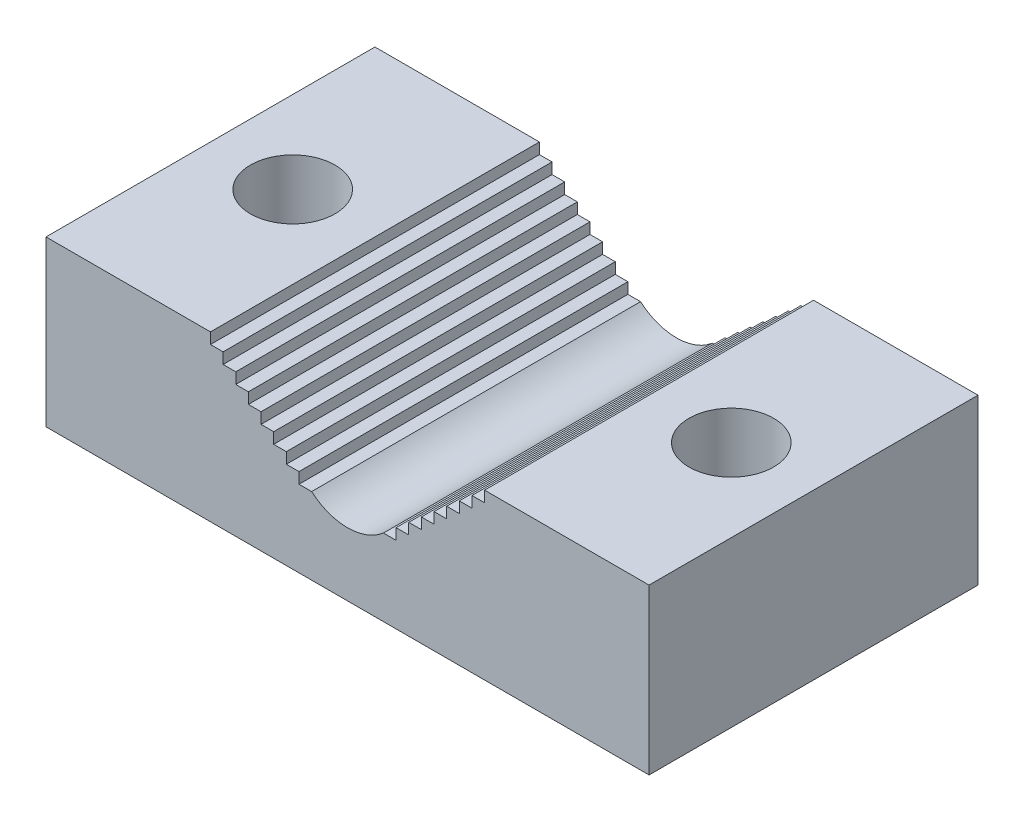
from build123d import *

# Parameters (mm, degrees)
SKETCH1_W               = 69.85
SKETCH1_H               = 19.05
BOSS_EXTRUDE1_DEPTH     = 38.1
CUT_EXTRUDE1_REACH      = 40.1
F_3_8_CLEARANCE_HOLE1_D = 9.8044


with BuildPart() as part:
    # Sketch1 → Boss-Extrude1 (new body)
    with BuildSketch(Plane.XY):
        with Locations((0, 9.525)):
            Rectangle(SKETCH1_W, SKETCH1_H)
    extrude(amount=-BOSS_EXTRUDE1_DEPTH)

    # Sketch2 → Cut-Extrude1 (cut, up to next)
    with BuildSketch(Plane.XY, mode=Mode.PRIVATE) as cut_extrude1_sk1:
        with BuildLine():
            Line((-15.875, 19.05), (0, 19.05))
            Line((0, 19.05), (15.875, 19.05))
            Line((15.875, 19.05), (15.875, 17.78))
            Line((15.875, 17.78), (14.410694861, 17.78))
            Line((14.410694861, 17.78), (14.410694861, 16.51))
            Line((14.410694861, 16.51), (12.946389723, 16.51))
            Line((12.946389723, 16.51), (12.946389723, 15.24))
            Line((12.946389723, 15.24), (11.482084584, 15.24))
            Line((11.482084584, 15.24), (11.482084584, 13.97))
            Line((11.482084584, 13.97), (10.017779445, 13.97))
            Line((10.017779445, 13.97), (10.017779445, 12.7))
            Line((10.017779445, 12.7), (8.553474306, 12.7))
            Line((8.553474306, 12.7), (8.553474306, 11.43))
            Line((8.553474306, 11.43), (7.089169168, 11.43))
            Line((7.089169168, 11.43), (7.089169168, 10.16))
            Line((7.089169168, 10.16), (5.624864029, 10.16))
            Line((5.624864029, 10.16), (5.624864029, 8.89))
            Line((5.624864029, 8.89), (4.16055889, 8.89))
            ThreePointArc((4.16055889, 8.89), (0, 7.337108475), (-4.16055889, 8.89))
            Line((-4.16055889, 8.89), (-5.624864029, 8.89))
            Line((-5.624864029, 8.89), (-5.624864029, 10.16))
            Line((-5.624864029, 10.16), (-7.089169168, 10.16))
            Line((-7.089169168, 10.16), (-7.089169168, 11.43))
            Line((-7.089169168, 11.43), (-8.553474306, 11.43))
            Line((-8.553474306, 11.43), (-8.553474306, 12.7))
            Line((-8.553474306, 12.7), (-10.017779445, 12.7))
            Line((-10.017779445, 12.7), (-10.017779445, 13.97))
            Line((-10.017779445, 13.97), (-11.482084584, 13.97))
            Line((-11.482084584, 13.97), (-11.482084584, 15.24))
            Line((-11.482084584, 15.24), (-12.946389723, 15.24))
            Line((-12.946389723, 15.24), (-12.946389723, 16.51))
            Line((-12.946389723, 16.51), (-14.410694861, 16.51))
            Line((-14.410694861, 16.51), (-14.410694861, 17.78))
            Line((-14.410694861, 17.78), (-15.875, 17.78))
            Line((-15.875, 17.78), (-15.875, 19.05))
        make_face()
    cut_extrude1_tool1 = extrude(cut_extrude1_sk1.sketch, amount=-CUT_EXTRUDE1_REACH, mode=Mode.PRIVATE) & part.part
    add(cut_extrude1_tool1.solids().sort_by_distance((0, 14.620592, 0))[0], mode=Mode.SUBTRACT)

    # 3/8 Clearance Hole1 (through all)
    with Locations(Plane(origin=(0, 19.05, 0), x_dir=(1, 0, 0), z_dir=(0, 1, 0))):
        with Locations((-25.4, 19.05), (25.4, 19.05)):
            Hole(F_3_8_CLEARANCE_HOLE1_D / 2)


solid = part.part
